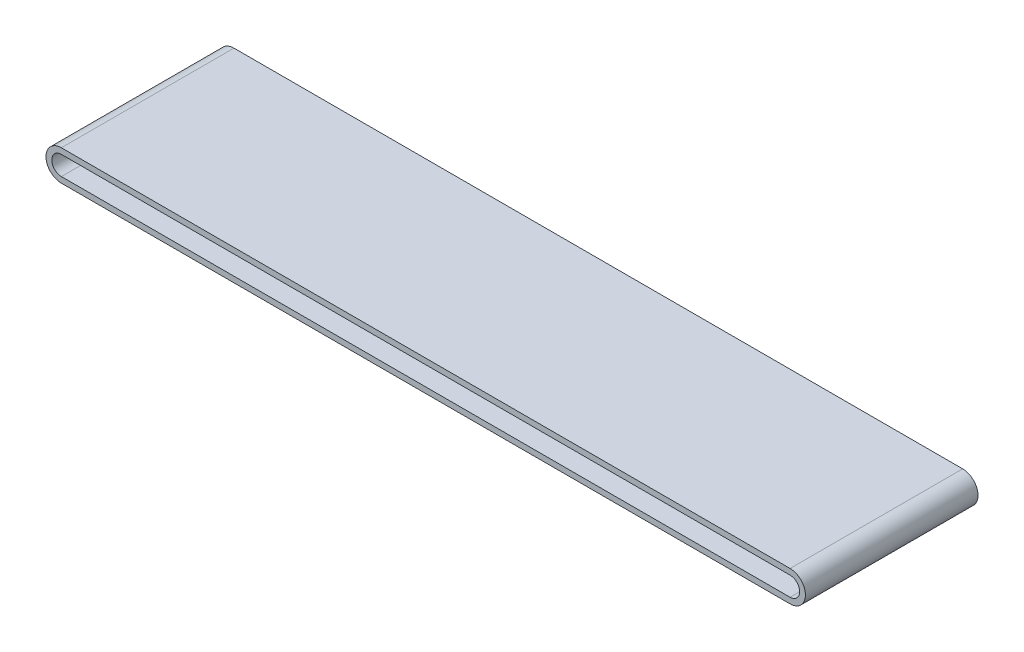
from build123d import *

# Parameters (mm, degrees)
EXTRUDE_1_DEPTH = 45


with BuildPart() as part:
    # 草图2 → 拉伸-薄壁1 (new, symmetric)
    with BuildSketch(Plane.XY):
        with BuildLine():
            Line((382.478085125, -8), (2.478085125, -8))
            ThreePointArc((2.478085125, -8), (-5.521914875, 0), (2.478085125, 8))
            Line((2.478085125, 8), (382.478085125, 8))
            ThreePointArc((382.478085125, 8), (390.478085125, 0), (382.478085125, -8))
        make_face()
        with BuildLine():
            Line((382.478085125, -5), (2.478085125, -5))
            ThreePointArc((2.478085125, -5), (-2.521914875, 0), (2.478085125, 5))
            Line((2.478085125, 5), (382.478085125, 5))
            ThreePointArc((382.478085125, 5), (387.478085125, 0), (382.478085125, -5))
        make_face(mode=Mode.SUBTRACT)
    extrude(amount=EXTRUDE_1_DEPTH, both=True)


solid = part.part
